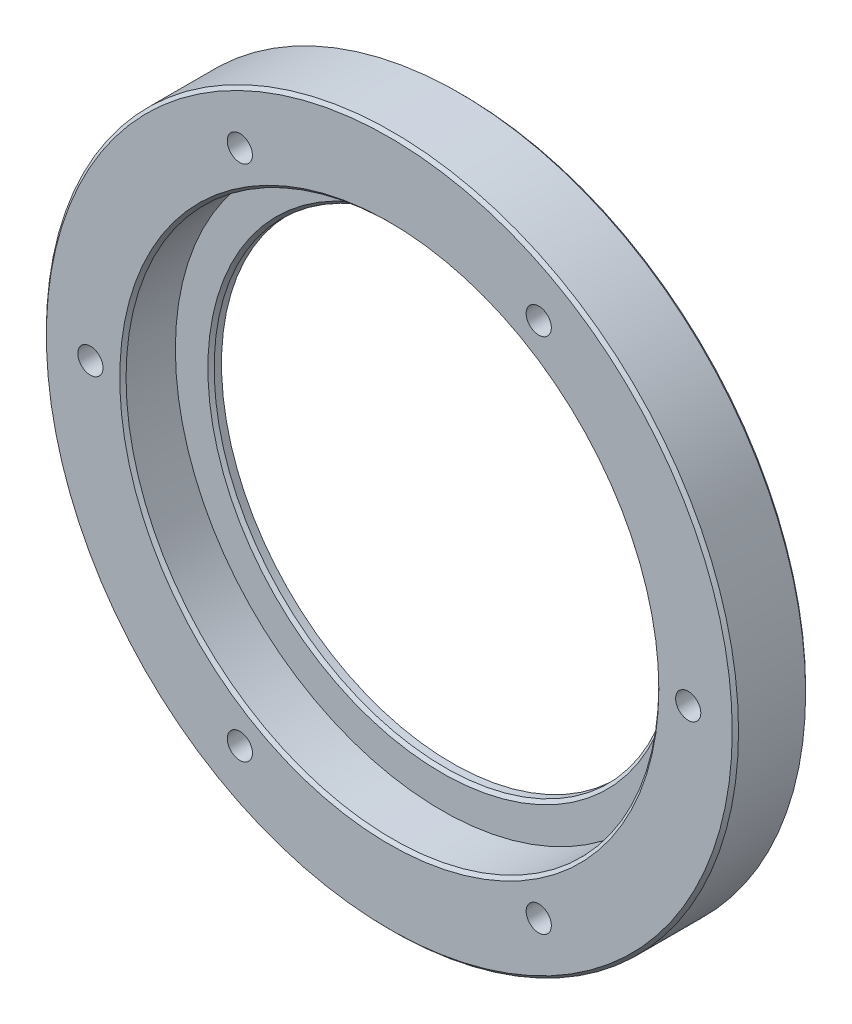
from build123d import *

# Parameters (mm, degrees)
SKETCH1_R                    = 33
MAIN_BODY_DEPTH              = 7
SKETCH2_R                    = 22
OPTICAL_CUTOUT_DEPTH         = 48.191100856
SKETCH3_R                    = 25.4
WINDOW_CUTOUT_DEPTH          = 5
SKETCH4_R                    = 1.2
CUT_EXTRUDE3_DEPTH           = 48.191100856
SKETCH5_R                    = 2.1
CUT_EXTRUDE4_DEPTH           = 2
CIRCULAR_PATTERN_COUNT       = 6
BUBBLE_CONTROL_CHAMFER_SIZE  = 1
BUBBLE_CONTROL_CHAMFER_SIZE2 = 2
CHAMFER1_SIZE                = 0.3


with BuildPart() as part:
    # Sketch1 → Main Body (new body)
    with BuildSketch(Plane.XY):
        Circle(SKETCH1_R)
    extrude(amount=MAIN_BODY_DEPTH)

    # Sketch2 → Optical Cutout (cut, through all)
    with BuildSketch(Plane.XY.offset(7)):
        Circle(SKETCH2_R)
    extrude(amount=-OPTICAL_CUTOUT_DEPTH, mode=Mode.SUBTRACT)

    # Sketch3 → Window Cutout (cut)
    with BuildSketch(Plane.XY.offset(7)):
        Circle(SKETCH3_R)
    extrude(amount=-WINDOW_CUTOUT_DEPTH, mode=Mode.SUBTRACT)

    # Sketch4 → Cut-Extrude3 (cut, through all)
    with BuildSketch(Plane(origin=(0, 0, 0), x_dir=(-1, 0, 0), z_dir=(0, 0, -1))):
        with Locations((14.25, 24.681724008)):
            Circle(SKETCH4_R)
    cut_extrude3 = extrude(amount=-CUT_EXTRUDE3_DEPTH, mode=Mode.SUBTRACT)

    # Sketch5 → Cut-Extrude4 (cut)
    with BuildSketch(Plane(origin=(0, 0, 0), x_dir=(-1, 0, 0), z_dir=(0, 0, -1))):
        with Locations((14.25, 24.681724008)):
            Circle(SKETCH5_R)
    cut_extrude4 = extrude(amount=-CUT_EXTRUDE4_DEPTH, mode=Mode.SUBTRACT)

    # Circular Pattern: Cut-Extrude3, Cut-Extrude4 ×6 about axis
    circular_pattern_axis = Axis((0, 0, 7), (0, 0, -1))
    add([cut_extrude3.rotate(circular_pattern_axis, i * 360 / CIRCULAR_PATTERN_COUNT) for i in range(1, CIRCULAR_PATTERN_COUNT)], mode=Mode.SUBTRACT)
    add([cut_extrude4.rotate(circular_pattern_axis, i * 360 / CIRCULAR_PATTERN_COUNT) for i in range(1, CIRCULAR_PATTERN_COUNT)], mode=Mode.SUBTRACT)

    # Bubble Control Chamfer
    bubble_control_chamfer_edges = [part.edges().sort_by_distance(p)[0] for p in [
        (-22, 0, 0),
    ]]
    bubble_control_chamfer_side = [part.faces().sort_by_distance(p)[0] for p in [
        (-22, 0, 1),
    ]]
    chamfer(bubble_control_chamfer_edges, length=BUBBLE_CONTROL_CHAMFER_SIZE, length2=BUBBLE_CONTROL_CHAMFER_SIZE2, reference=bubble_control_chamfer_side[0])

    # Chamfer1
    chamfer1_edges = [part.edges().sort_by_distance(p)[0] for p in [
        (-33, 0, 0),
        (-33, 0, 7),
        (-25.4, 0, 7),
        (-22, 0, 2),
    ]]
    chamfer(chamfer1_edges, length=CHAMFER1_SIZE)


solid = part.part
